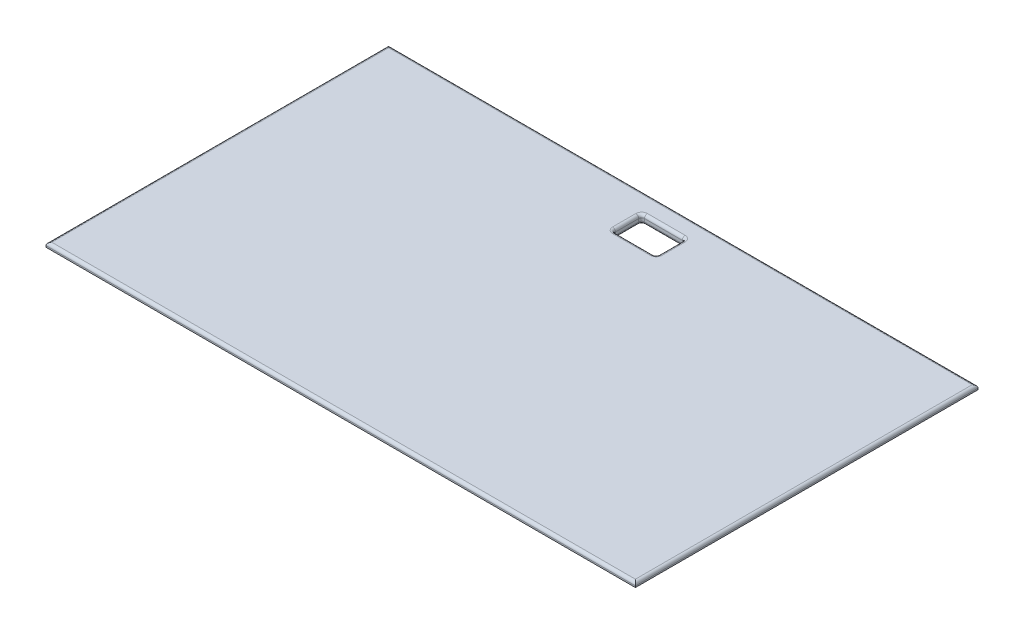
from build123d import *

# Parameters (mm, degrees)
SKETCH_1_W          = 200
SKETCH_1_H          = 115
EXTRUDE_1_DEPTH     = 1.5
SKETCH_2_W          = 203
SKETCH_2_H          = 118
EXTRUDE_2_DEPTH     = 1.5
SKETCH_3_W          = 15
SKETCH_3_H          = 10
CUT_EXTRUDE_1_DEPTH = 11.5
FILLET_2_R          = 1
FILLET_3_R          = 1
SKETCH_4_W          = 8
SKETCH_4_H          = 1.5
EXTRUDE_3_DEPTH     = 5


with BuildPart() as part:
    # 草图1 → 凸台-拉伸1 (new body)
    with BuildSketch(Plane(origin=(0, 0, 0), x_dir=(1, 0, 0), z_dir=(0, 1, 0))):
        Rectangle(SKETCH_1_W, SKETCH_1_H)
    extrude(amount=EXTRUDE_1_DEPTH)

    # 草图2 → 凸台-拉伸2 (add)
    with BuildSketch(Plane(origin=(0, 1.5, 0), x_dir=(1, 0, 0), z_dir=(0, 1, 0))):
        Rectangle(SKETCH_2_W, SKETCH_2_H)
    extrude(amount=EXTRUDE_2_DEPTH)

    # 草图3 → 切除-拉伸1 (cut)
    with BuildSketch(Plane.XZ):
        with Locations((0, -47.14798892)):
            Rectangle(SKETCH_3_W, SKETCH_3_H)
    extrude(amount=-CUT_EXTRUDE_1_DEPTH, mode=Mode.SUBTRACT)

    # 圆角2
    fillet_2_edges = [part.edges().sort_by_distance(p)[0] for p in [
        (0, 3, -42.14798892),
        (-7.5, 3, -47.14798892),
        (0, 3, -52.14798892),
        (7.5, 3, -47.14798892),
        (7.5, 1.5, -42.14798892),
        (7.5, 1.5, -52.14798892),
        (-7.5, 1.5, -52.14798892),
        (-7.5, 1.5, -42.14798892),
        (7.5, 0, -47.14798892),
        (0, 0, -42.14798892),
        (-7.5, 0, -47.14798892),
        (0, 0, -52.14798892),
    ]]
    fillet(fillet_2_edges, radius=FILLET_2_R)

    # 圆角3
    fillet_3_edges = [part.edges().sort_by_distance(p)[0] for p in [
        (101.5, 3, 0),
        (0, 3, -59),
        (-101.5, 3, 0),
        (0, 3, 59),
    ]]
    fillet(fillet_3_edges, radius=FILLET_3_R)

    # 草图4 → 凸台-拉伸3 (add)
    with BuildSketch(Plane.XZ):
        Polygon((-64.695285942, 41.001921469), (-64.695285942, 42.501921469), (-71.195285942, 42.501921469), (-71.195285942, 36.001921469), (-69.695285942, 36.001921469), (-69.695285942, 41.001921469), align=None)
        Polygon((-21.25, -1.493976955), (-21.25, 0.006023045), (-27.75, 0.006023045), (-27.75, -6.493976955), (-26.25, -6.493976955), (-26.25, -1.493976955), align=None)
        Polygon((-32.195285942, 41.001921469), (-32.195285942, 42.501921469), (-25.695285942, 42.501921469), (-25.695285942, 36.001921469), (-27.195285942, 36.001921469), (-27.195285942, 41.001921469), align=None)
        Polygon((-25.695285942, 22.001921469), (-27.195285942, 22.001921469), (-27.195285942, 17.001921469), (-32.195285942, 17.001921469), (-32.195285942, 15.501921469), (-25.695285942, 15.501921469), align=None)
        Polygon((-71.195285942, 22.001921469), (-69.695285942, 22.001921469), (-69.695285942, 17.001921469), (-64.695285942, 17.001921469), (-64.695285942, 15.501921469), (-71.195285942, 15.501921469), align=None)
        Polygon((27.75, -6.493976955), (26.25, -6.493976955), (26.25, -1.493976955), (21.25, -1.493976955), (21.25, 0.006023045), (27.75, 0.006023045), align=None)
        Polygon((-26.25, -30.293976955), (-21.25, -30.293976955), (-21.25, -31.793976955), (-27.75, -31.793976955), (-27.75, -25.293976955), (-26.25, -25.293976955), align=None)
        Polygon((21.25, -30.293976955), (21.25, -31.793976955), (27.75, -31.793976955), (27.75, -25.293976955), (26.25, -25.293976955), (26.25, -30.293976955), align=None)
        with Locations((52.085748654, 44.501921469)):
            Rectangle(SKETCH_4_W, SKETCH_4_H)
        Polygon((25.335748654, 19.251921469), (23.835748654, 19.251921469), (23.835748654, 12.751921469), (30.335748654, 12.751921469), (30.335748654, 14.251921469), (25.335748654, 14.251921469), align=None)
        Polygon((73.835748654, 12.751921469), (73.835748654, 14.251921469), (78.835748654, 14.251921469), (78.835748654, 19.251921469), (80.335748654, 19.251921469), (80.335748654, 12.751921469), align=None)
    extrude(amount=EXTRUDE_3_DEPTH)


solid = part.part
